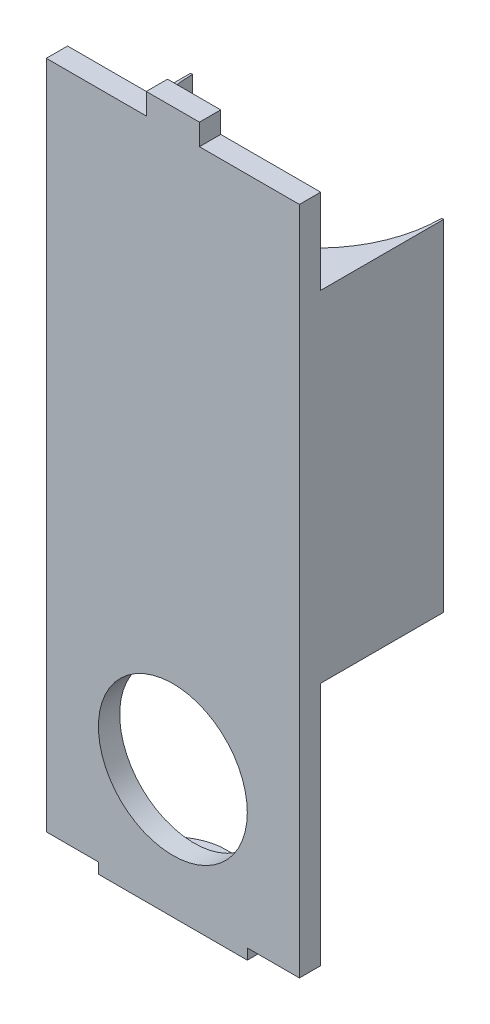
from build123d import *

# Parameters (mm, degrees)
BOSS_EXTRUDE1_DEPTH = 32
SKETCH2_W           = 13.568258361
SKETCH2_H           = 32
CUT_EXTRUDE1_DEPTH  = 2.1
SKETCH3_W           = 23.8
SKETCH3_H           = 2
BOSS_EXTRUDE2_DEPTH = 23
SKETCH4_W           = 23.8
SKETCH4_H           = 2
BOSS_EXTRUDE3_DEPTH = 8
CUT_EXTRUDE2_REACH  = 15.568
SKETCH5_R           = 7
SKETCH6_W           = 2.5
SKETCH6_H           = 2
BOSS_EXTRUDE4_DEPTH = 2
SKETCH7_W           = 7
SKETCH7_H           = 2
BOSS_EXTRUDE5_DEPTH = 1
BOSS_EXTRUDE6_START = -2
SKETCH8_W           = 14
SKETCH8_H           = 1
BOSS_EXTRUDE6_DEPTH = 5
CUT_EXTRUDE3_REACH  = 68
SKETCH9_R           = 1.5
FILLET1_R           = 5


with BuildPart() as part:
    # Sketch1 → Boss-Extrude1 (new body)
    with BuildSketch(Plane(origin=(0, 0, 0), x_dir=(1, 0, 0), z_dir=(0, 1, 0))):
        with BuildLine():
            Line((14, -0.431741639), (11.721082209, -0.431741639))
            ThreePointArc((11.721082209, -0.431741639), (10.883203702, -4.783711919), (8.489359235, -8.513483277))
            Line((8.489359235, -8.513483277), (-8.489359235, -8.513483277))
            ThreePointArc((-8.489359235, -8.513483277), (-10.883203702, -4.783711919), (-11.721082209, -0.431741639))
            Line((-11.721082209, -0.431741639), (-14, -0.431741639))
            Line((-14, -0.431741639), (-14, -14))
            Line((-14, -14), (14, -14))
            Line((14, -14), (14, -0.431741639))
        make_face()
    extrude(amount=BOSS_EXTRUDE1_DEPTH)

    # Sketch2 → Cut-Extrude1 (cut)
    with BuildSketch(Plane.ZY.offset(14)):
        with Locations((7.21587082, 16)):
            Rectangle(SKETCH2_W, SKETCH2_H)
    cut_extrude1 = extrude(amount=-CUT_EXTRUDE1_DEPTH, mode=Mode.SUBTRACT)

    # Mirror1: Cut-Extrude1 across plane
    add(cut_extrude1.mirror(Plane(origin=(0, 0, 0), x_dir=(0, 0, 1), z_dir=(1, 0, 0))), mode=Mode.SUBTRACT)

    # Sketch3 → Boss-Extrude2 (add)
    with BuildSketch(Plane.XZ):
        with Locations((0, 13)):
            Rectangle(SKETCH3_W, SKETCH3_H)
    extrude(amount=BOSS_EXTRUDE2_DEPTH)

    # Sketch4 → Boss-Extrude3 (add)
    with BuildSketch(Plane(origin=(0, 32, 0), x_dir=(1, 0, 0), z_dir=(0, 1, 0))):
        with Locations((0, -13)):
            Rectangle(SKETCH4_W, SKETCH4_H)
    extrude(amount=BOSS_EXTRUDE3_DEPTH)

    # Sketch5 → Cut-Extrude2 (cut, up to next)
    with BuildSketch(Plane.XY.offset(14), mode=Mode.PRIVATE) as cut_extrude2_sk1:
        with Locations((0, -11.97008474)):
            Circle(SKETCH5_R)
    cut_extrude2_tool1 = extrude(cut_extrude2_sk1.sketch, amount=-CUT_EXTRUDE2_REACH, mode=Mode.PRIVATE) & part.part
    add(cut_extrude2_tool1.solids().sort_by_distance((0, -11.970085, 14))[0], mode=Mode.SUBTRACT)

    # Sketch6 → Boss-Extrude4 (add)
    with BuildSketch(Plane(origin=(0, 40, 0), x_dir=(1, 0, 0), z_dir=(0, 1, 0))):
        with Locations((-1.25, -13)):
            Rectangle(SKETCH6_W, SKETCH6_H)
        with Locations((1.25, -13)):
            Rectangle(SKETCH6_W, SKETCH6_H)
    extrude(amount=BOSS_EXTRUDE4_DEPTH)

    # Sketch7 → Boss-Extrude5 (add)
    with BuildSketch(Plane.XZ.offset(23)):
        with Locations((3.5, 13)):
            Rectangle(SKETCH7_W, SKETCH7_H)
        with Locations((-3.5, 13)):
            Rectangle(SKETCH7_W, SKETCH7_H)
    extrude(amount=BOSS_EXTRUDE5_DEPTH)

    # Sketch8 → Boss-Extrude6 (add)
    with BuildSketch(Plane.XY.offset(14).offset(BOSS_EXTRUDE6_START)):
        with Locations((0, -23.5)):
            Rectangle(SKETCH8_W, SKETCH8_H)
    extrude(amount=-BOSS_EXTRUDE6_DEPTH)

    # Sketch9 → Cut-Extrude3 (cut, up to next)
    with BuildSketch(Plane.XZ.offset(24), mode=Mode.PRIVATE) as cut_extrude3_sk1:
        with Locations((0, 9.5)):
            Circle(SKETCH9_R)
    cut_extrude3_tool1 = extrude(cut_extrude3_sk1.sketch, amount=-CUT_EXTRUDE3_REACH, mode=Mode.PRIVATE) & part.part
    add(cut_extrude3_tool1.solids().sort_by_distance((0, -24, 9.5))[0], mode=Mode.SUBTRACT)

    # Fillet1
    fillet1_edges = [part.edges().sort_by_distance(p)[0] for p in [
        (-7, -23.5, 7),
        (7, -23.5, 7),
    ]]
    fillet(fillet1_edges, radius=FILLET1_R)


solid = part.part
